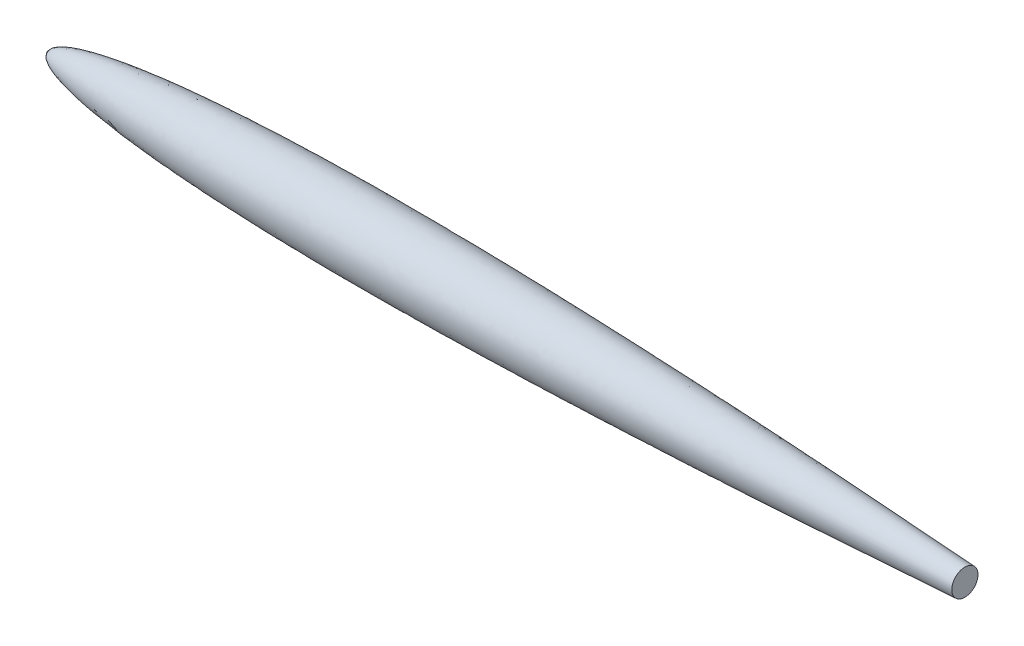
from build123d import *

# Parameters (mm, degrees)
CUTSKETCH_R        = 274.5
CUT_EXTRUDE1_DEPTH = 1648.0000001


with BuildPart() as part:
    # rootSketch → Revolve1 (revolve)
    with BuildSketch(Plane(origin=(0, 0, 0), x_dir=(1, 0, 0), z_dir=(0, 1, 0))):
        with BuildLine():
            Line((0, 0), (9150, 0))
            add(Edge.make_bspline(
                [(0, 0), (0.000160612, 1.178338668), (0.101927429, 3.527546875), (0.560540129, 7.032762128), (1.754850899, 11.594263448), (3.435425658, 15.899983247), (5.499066319, 19.933959303), (8.311039095, 24.428945776), (11.485219555, 28.590828066), (14.976932189, 32.50948125), (19.969099058, 37.44219556), (26.93755643, 43.450361558), (36.087640326, 50.070782057), (47.476912242, 57.077759188), (61.540387156, 64.652473124), (77.183799538, 72.071636941), (94.792158043, 79.45256662), (114.338032981, 86.767844958), (138.330950586, 94.94042848), (167.437529655, 103.839028072), (202.19021179, 113.297577183), (242.618908211, 123.079119609), (283.85237063, 132.074401946), (324.914851639, 140.247080301), (365.766389078, 147.738368505), (416.451146253, 156.365751208), (477.022127198, 165.766869274), (547.845629726, 175.668869941), (630.588182863, 186.00110632), (715.101408629, 195.473660488), (801.36280682, 204.181856395), (889.35557409, 212.199179233), (977.413477894, 219.463094498), (1065.523951613, 226.056192188), (1153.677402277, 232.045348732), (1241.866295097, 237.485951633), (1352.184475076, 243.661385297), (1484.651724521, 250.147610485), (1639.281632973, 256.512937248), (1816.080414931, 262.344959236), (1992.916414639, 266.897490578), (2169.777939711, 270.304082119), (2346.656177774, 272.675700655), (2523.544368397, 274.106433958), (2744.66055408, 274.819477986), (3010.001312139, 274.095543923), (3319.553789887, 271.216223434), (3673.296781268, 265.523933355), (4026.999477835, 257.744990519), (4380.656831985, 248.137527842), (4734.266305229, 236.914341825), (5087.826900398, 224.250429382), (5441.338456238, 210.288408279), (5794.801148288, 195.142305772), (6148.215104246, 178.900408204), (6501.580112325, 161.627361411), (6810.730974752, 145.648489217), (7075.685369906, 131.348153783), (7296.458530996, 119.029096191), (7473.063386989, 108.931656651), (7649.654093753, 98.589922493), (7826.230154186, 88.000635748), (7980.720793582, 78.514563511), (8113.131405924, 70.222733955), (8223.466573069, 63.20354654), (8311.730622771, 57.521688204), (8399.989953528, 51.772397348), (8488.245445279, 45.954572173), (8565.463885668, 40.803168085), (8631.649893589, 36.343336289), (8686.800104424, 32.597150054), (8730.924004516, 29.58176595), (8775.036611273, 26.548875536), (8819.165790844, 23.496286414), (8863.263373244, 20.427327998), (8907.410710771, 17.335912578), (8951.468898618, 14.231955542), (8990.160782109, 11.488944565), (9023.096897261, 9.142268217), (9050.904900655, 7.152311591), (9072.498802607, 5.602858669), (9095.442400122, 3.95038404), (9115.835188706, 2.478332147), (9134.825858835, 1.101944003), (9144.986407858, 0.364362809), (9150, 0)],
                knots=[0, 0, 0, 0, 0, 0.000464454, 0.000928907, 0.001393361, 0.001857814, 0.002287128, 0.002716441, 0.003486019, 0.003922473, 0.004358926, 0.005488094, 0.007117503, 0.008377929, 0.009638355, 0.011796648, 0.013954941, 0.015918589, 0.017882237, 0.021809533, 0.025977713, 0.030145893, 0.034314073, 0.038482253, 0.042518279, 0.046554305, 0.054626357, 0.062698409, 0.070770462, 0.079497478, 0.088224494, 0.09695151, 0.105678526, 0.114405542, 0.123132558, 0.131859574, 0.14058659, 0.158058513, 0.175530436, 0.193002359, 0.210474282, 0.227946206, 0.24541813, 0.262890054, 0.280361977, 0.315305825, 0.350249672, 0.38519352, 0.420137368, 0.455081215, 0.490025063, 0.524968911, 0.559912758, 0.594856606, 0.629800453, 0.664744301, 0.699688149, 0.717160073, 0.734631996, 0.75210392, 0.769575844, 0.787047768, 0.804519691, 0.813255653, 0.821991615, 0.830727577, 0.839463539, 0.848199501, 0.856935463, 0.861303444, 0.865671425, 0.870039406, 0.874407387, 0.878775368, 0.883143349, 0.88751133, 0.891879311, 0.896247292, 0.898431282, 0.900615273, 0.902799263, 0.904983254, 0.907167244, 0.909351235, 0.909351235, 0.909351235, 0.909351235, 0.909351235], degree=4))
        make_face()
    revolve(axis=Axis((0, 0, 0), (1, 0, 0)))

    # cutSketch → Cut-Extrude1 (cut, through all)
    with BuildSketch(Plane(origin=(7503, 0, 0), x_dir=(0, 0, -1), z_dir=(1, 0, 0))):
        Circle(CUTSKETCH_R)
    extrude(amount=CUT_EXTRUDE1_DEPTH, mode=Mode.SUBTRACT)


solid = part.part
